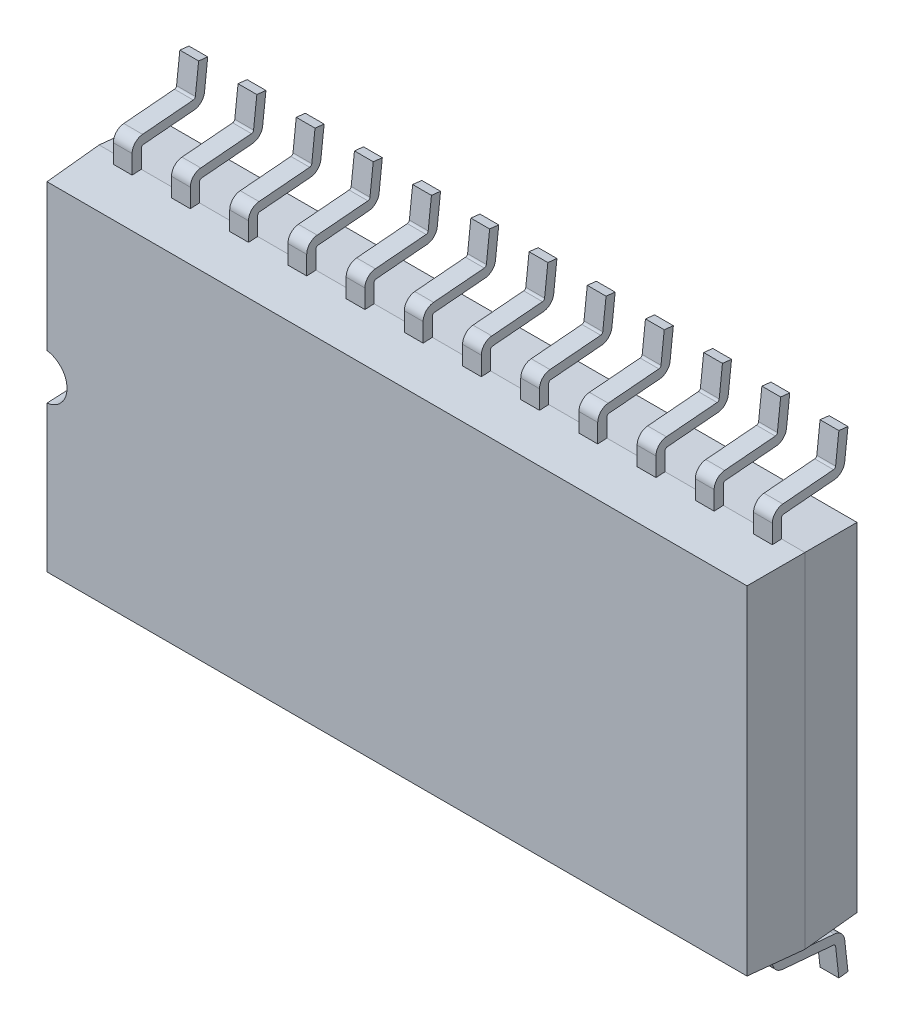
from build123d import *

# Parameters (mm, degrees)
SKETCH1_W             = 15.4
SKETCH1_H             = 7.5
BOSS_EXTRUDE1_DEPTH   = 1.2
BOSS_EXTRUDE1_TAPER   = 3
SKETCH2_W             = 15.4
SKETCH2_H             = 7.5
BOSS_EXTRUDE2_DEPTH   = 1.2
BOSS_EXTRUDE2_TAPER   = 3
EXTRUDE_THIN1_DEPTH   = 0.205
LPATTERN1_COUNT       = 12
LPATTERN1_PITCH       = 1.27
MIRROR1_COPY_1_DEPTH  = 0.205
MIRROR1_COPY_2_DEPTH  = 0.205
MIRROR1_COPY_3_DEPTH  = 0.205
MIRROR1_COPY_4_DEPTH  = 0.205
MIRROR1_COPY_5_DEPTH  = 0.205
MIRROR1_COPY_6_DEPTH  = 0.205
MIRROR1_COPY_7_DEPTH  = 0.205
MIRROR1_COPY_8_DEPTH  = 0.205
MIRROR1_COPY_9_DEPTH  = 0.205
MIRROR1_COPY_10_DEPTH = 0.205
MIRROR1_COPY_11_DEPTH = 0.205
CUT_EXTRUDE4_DEPTH    = 2.2


with BuildPart() as part:
    # Sketch1 → Boss-Extrude1 (new body)
    with BuildSketch(Plane.XY):
        with Locations((7.7, 3.75)):
            Rectangle(SKETCH1_W, SKETCH1_H)
    extrude(amount=BOSS_EXTRUDE1_DEPTH, taper=BOSS_EXTRUDE1_TAPER)

    # Sketch2 → Boss-Extrude2 (add)
    with BuildSketch(Plane(origin=(0, 0, 0), x_dir=(-1, 0, 0), z_dir=(0, 0, -1))):
        with Locations((-7.7, 3.75)):
            Rectangle(SKETCH2_W, SKETCH2_H)
    extrude(amount=BOSS_EXTRUDE2_DEPTH, taper=BOSS_EXTRUDE2_TAPER)

    # Sketch3 → Extrude-Thin1 (add, symmetric)
    with BuildSketch(Plane(origin=(0.715, 0, 0), x_dir=(0, 0, -1), z_dir=(1, 0, 0))):
        with BuildLine():
            Line((0, 0.17480102), (0, -0.397438223))
            ThreePointArc((0, -0.397438223), (0.013160257, -0.431244042), (0.045713334, -0.447254129))
            Line((0.045713334, -0.447254129), (1.151740198, -0.542427897))
            ThreePointArc((1.151740198, -0.542427897), (1.304800704, -0.612476978), (1.378754382, -0.763689564))
            Line((1.378754382, -0.763689564), (1.45, -1.4))
            Line((1.45, -1.4), (1.25124199, -1.422254291))
            Line((1.25124199, -1.422254291), (1.179996372, -0.785943854))
            ThreePointArc((1.179996372, -0.785943854), (1.165205636, -0.755701337), (1.134593535, -0.741691521))
            Line((1.134593535, -0.741691521), (0.028566671, -0.646517754))
            ThreePointArc((0.028566671, -0.646517754), (-0.134198714, -0.566467315), (-0.2, -0.397438223))
            Line((-0.2, -0.397438223), (-0.2, 0.17480102))
            Line((-0.2, 0.17480102), (0, 0.17480102))
        make_face()
    extrude_thin1 = extrude(amount=EXTRUDE_THIN1_DEPTH, both=True)

    # LPattern1: Extrude-Thin1 ×12
    with Locations(*[(i * LPATTERN1_PITCH, 0, 0) for i in range(1, LPATTERN1_COUNT)]):
        add(extrude_thin1)

    # Mirror1: Extrude-Thin1 across plane
    add(extrude_thin1.mirror(Plane.ZX.offset(3.75)))

    # Mirror1 copy 1 sketch → Mirror1 copy 1 (add, symmetric)
    with BuildSketch(Plane(origin=(1.985, 7.5, 0), x_dir=(0, 0, -1), z_dir=(1, 0, 0))):
        with BuildLine():
            Line((0, -0.17480102), (0, 0.397438223))
            ThreePointArc((0, 0.397438223), (0.013160257, 0.431244042), (0.045713334, 0.447254129))
            Line((0.045713334, 0.447254129), (1.151740198, 0.542427897))
            ThreePointArc((1.151740198, 0.542427897), (1.304800704, 0.612476978), (1.378754382, 0.763689564))
            Line((1.378754382, 0.763689564), (1.45, 1.4))
            Line((1.45, 1.4), (1.25124199, 1.422254291))
            Line((1.25124199, 1.422254291), (1.179996372, 0.785943854))
            ThreePointArc((1.179996372, 0.785943854), (1.165205636, 0.755701337), (1.134593535, 0.741691521))
            Line((1.134593535, 0.741691521), (0.028566671, 0.646517754))
            ThreePointArc((0.028566671, 0.646517754), (-0.134198714, 0.566467315), (-0.2, 0.397438223))
            Line((-0.2, 0.397438223), (-0.2, -0.17480102))
            Line((-0.2, -0.17480102), (0, -0.17480102))
        make_face()
    extrude(amount=MIRROR1_COPY_1_DEPTH, both=True)

    # Mirror1 copy 2 sketch → Mirror1 copy 2 (add, symmetric)
    with BuildSketch(Plane(origin=(3.255, 7.5, 0), x_dir=(0, 0, -1), z_dir=(1, 0, 0))):
        with BuildLine():
            Line((0, -0.17480102), (0, 0.397438223))
            ThreePointArc((0, 0.397438223), (0.013160257, 0.431244042), (0.045713334, 0.447254129))
            Line((0.045713334, 0.447254129), (1.151740198, 0.542427897))
            ThreePointArc((1.151740198, 0.542427897), (1.304800704, 0.612476978), (1.378754382, 0.763689564))
            Line((1.378754382, 0.763689564), (1.45, 1.4))
            Line((1.45, 1.4), (1.25124199, 1.422254291))
            Line((1.25124199, 1.422254291), (1.179996372, 0.785943854))
            ThreePointArc((1.179996372, 0.785943854), (1.165205636, 0.755701337), (1.134593535, 0.741691521))
            Line((1.134593535, 0.741691521), (0.028566671, 0.646517754))
            ThreePointArc((0.028566671, 0.646517754), (-0.134198714, 0.566467315), (-0.2, 0.397438223))
            Line((-0.2, 0.397438223), (-0.2, -0.17480102))
            Line((-0.2, -0.17480102), (0, -0.17480102))
        make_face()
    extrude(amount=MIRROR1_COPY_2_DEPTH, both=True)

    # Mirror1 copy 3 sketch → Mirror1 copy 3 (add, symmetric)
    with BuildSketch(Plane(origin=(4.525, 7.5, 0), x_dir=(0, 0, -1), z_dir=(1, 0, 0))):
        with BuildLine():
            Line((0, -0.17480102), (0, 0.397438223))
            ThreePointArc((0, 0.397438223), (0.013160257, 0.431244042), (0.045713334, 0.447254129))
            Line((0.045713334, 0.447254129), (1.151740198, 0.542427897))
            ThreePointArc((1.151740198, 0.542427897), (1.304800704, 0.612476978), (1.378754382, 0.763689564))
            Line((1.378754382, 0.763689564), (1.45, 1.4))
            Line((1.45, 1.4), (1.25124199, 1.422254291))
            Line((1.25124199, 1.422254291), (1.179996372, 0.785943854))
            ThreePointArc((1.179996372, 0.785943854), (1.165205636, 0.755701337), (1.134593535, 0.741691521))
            Line((1.134593535, 0.741691521), (0.028566671, 0.646517754))
            ThreePointArc((0.028566671, 0.646517754), (-0.134198714, 0.566467315), (-0.2, 0.397438223))
            Line((-0.2, 0.397438223), (-0.2, -0.17480102))
            Line((-0.2, -0.17480102), (0, -0.17480102))
        make_face()
    extrude(amount=MIRROR1_COPY_3_DEPTH, both=True)

    # Mirror1 copy 4 sketch → Mirror1 copy 4 (add, symmetric)
    with BuildSketch(Plane(origin=(5.795, 7.5, 0), x_dir=(0, 0, -1), z_dir=(1, 0, 0))):
        with BuildLine():
            Line((0, -0.17480102), (0, 0.397438223))
            ThreePointArc((0, 0.397438223), (0.013160257, 0.431244042), (0.045713334, 0.447254129))
            Line((0.045713334, 0.447254129), (1.151740198, 0.542427897))
            ThreePointArc((1.151740198, 0.542427897), (1.304800704, 0.612476978), (1.378754382, 0.763689564))
            Line((1.378754382, 0.763689564), (1.45, 1.4))
            Line((1.45, 1.4), (1.25124199, 1.422254291))
            Line((1.25124199, 1.422254291), (1.179996372, 0.785943854))
            ThreePointArc((1.179996372, 0.785943854), (1.165205636, 0.755701337), (1.134593535, 0.741691521))
            Line((1.134593535, 0.741691521), (0.028566671, 0.646517754))
            ThreePointArc((0.028566671, 0.646517754), (-0.134198714, 0.566467315), (-0.2, 0.397438223))
            Line((-0.2, 0.397438223), (-0.2, -0.17480102))
            Line((-0.2, -0.17480102), (0, -0.17480102))
        make_face()
    extrude(amount=MIRROR1_COPY_4_DEPTH, both=True)

    # Mirror1 copy 5 sketch → Mirror1 copy 5 (add, symmetric)
    with BuildSketch(Plane(origin=(7.065, 7.5, 0), x_dir=(0, 0, -1), z_dir=(1, 0, 0))):
        with BuildLine():
            Line((0, -0.17480102), (0, 0.397438223))
            ThreePointArc((0, 0.397438223), (0.013160257, 0.431244042), (0.045713334, 0.447254129))
            Line((0.045713334, 0.447254129), (1.151740198, 0.542427897))
            ThreePointArc((1.151740198, 0.542427897), (1.304800704, 0.612476978), (1.378754382, 0.763689564))
            Line((1.378754382, 0.763689564), (1.45, 1.4))
            Line((1.45, 1.4), (1.25124199, 1.422254291))
            Line((1.25124199, 1.422254291), (1.179996372, 0.785943854))
            ThreePointArc((1.179996372, 0.785943854), (1.165205636, 0.755701337), (1.134593535, 0.741691521))
            Line((1.134593535, 0.741691521), (0.028566671, 0.646517754))
            ThreePointArc((0.028566671, 0.646517754), (-0.134198714, 0.566467315), (-0.2, 0.397438223))
            Line((-0.2, 0.397438223), (-0.2, -0.17480102))
            Line((-0.2, -0.17480102), (0, -0.17480102))
        make_face()
    extrude(amount=MIRROR1_COPY_5_DEPTH, both=True)

    # Mirror1 copy 6 sketch → Mirror1 copy 6 (add, symmetric)
    with BuildSketch(Plane(origin=(8.335, 7.5, 0), x_dir=(0, 0, -1), z_dir=(1, 0, 0))):
        with BuildLine():
            Line((0, -0.17480102), (0, 0.397438223))
            ThreePointArc((0, 0.397438223), (0.013160257, 0.431244042), (0.045713334, 0.447254129))
            Line((0.045713334, 0.447254129), (1.151740198, 0.542427897))
            ThreePointArc((1.151740198, 0.542427897), (1.304800704, 0.612476978), (1.378754382, 0.763689564))
            Line((1.378754382, 0.763689564), (1.45, 1.4))
            Line((1.45, 1.4), (1.25124199, 1.422254291))
            Line((1.25124199, 1.422254291), (1.179996372, 0.785943854))
            ThreePointArc((1.179996372, 0.785943854), (1.165205636, 0.755701337), (1.134593535, 0.741691521))
            Line((1.134593535, 0.741691521), (0.028566671, 0.646517754))
            ThreePointArc((0.028566671, 0.646517754), (-0.134198714, 0.566467315), (-0.2, 0.397438223))
            Line((-0.2, 0.397438223), (-0.2, -0.17480102))
            Line((-0.2, -0.17480102), (0, -0.17480102))
        make_face()
    extrude(amount=MIRROR1_COPY_6_DEPTH, both=True)

    # Mirror1 copy 7 sketch → Mirror1 copy 7 (add, symmetric)
    with BuildSketch(Plane(origin=(9.605, 7.5, 0), x_dir=(0, 0, -1), z_dir=(1, 0, 0))):
        with BuildLine():
            Line((0, -0.17480102), (0, 0.397438223))
            ThreePointArc((0, 0.397438223), (0.013160257, 0.431244042), (0.045713334, 0.447254129))
            Line((0.045713334, 0.447254129), (1.151740198, 0.542427897))
            ThreePointArc((1.151740198, 0.542427897), (1.304800704, 0.612476978), (1.378754382, 0.763689564))
            Line((1.378754382, 0.763689564), (1.45, 1.4))
            Line((1.45, 1.4), (1.25124199, 1.422254291))
            Line((1.25124199, 1.422254291), (1.179996372, 0.785943854))
            ThreePointArc((1.179996372, 0.785943854), (1.165205636, 0.755701337), (1.134593535, 0.741691521))
            Line((1.134593535, 0.741691521), (0.028566671, 0.646517754))
            ThreePointArc((0.028566671, 0.646517754), (-0.134198714, 0.566467315), (-0.2, 0.397438223))
            Line((-0.2, 0.397438223), (-0.2, -0.17480102))
            Line((-0.2, -0.17480102), (0, -0.17480102))
        make_face()
    extrude(amount=MIRROR1_COPY_7_DEPTH, both=True)

    # Mirror1 copy 8 sketch → Mirror1 copy 8 (add, symmetric)
    with BuildSketch(Plane(origin=(10.875, 7.5, 0), x_dir=(0, 0, -1), z_dir=(1, 0, 0))):
        with BuildLine():
            Line((0, -0.17480102), (0, 0.397438223))
            ThreePointArc((0, 0.397438223), (0.013160257, 0.431244042), (0.045713334, 0.447254129))
            Line((0.045713334, 0.447254129), (1.151740198, 0.542427897))
            ThreePointArc((1.151740198, 0.542427897), (1.304800704, 0.612476978), (1.378754382, 0.763689564))
            Line((1.378754382, 0.763689564), (1.45, 1.4))
            Line((1.45, 1.4), (1.25124199, 1.422254291))
            Line((1.25124199, 1.422254291), (1.179996372, 0.785943854))
            ThreePointArc((1.179996372, 0.785943854), (1.165205636, 0.755701337), (1.134593535, 0.741691521))
            Line((1.134593535, 0.741691521), (0.028566671, 0.646517754))
            ThreePointArc((0.028566671, 0.646517754), (-0.134198714, 0.566467315), (-0.2, 0.397438223))
            Line((-0.2, 0.397438223), (-0.2, -0.17480102))
            Line((-0.2, -0.17480102), (0, -0.17480102))
        make_face()
    extrude(amount=MIRROR1_COPY_8_DEPTH, both=True)

    # Mirror1 copy 9 sketch → Mirror1 copy 9 (add, symmetric)
    with BuildSketch(Plane(origin=(12.145, 7.5, 0), x_dir=(0, 0, -1), z_dir=(1, 0, 0))):
        with BuildLine():
            Line((0, -0.17480102), (0, 0.397438223))
            ThreePointArc((0, 0.397438223), (0.013160257, 0.431244042), (0.045713334, 0.447254129))
            Line((0.045713334, 0.447254129), (1.151740198, 0.542427897))
            ThreePointArc((1.151740198, 0.542427897), (1.304800704, 0.612476978), (1.378754382, 0.763689564))
            Line((1.378754382, 0.763689564), (1.45, 1.4))
            Line((1.45, 1.4), (1.25124199, 1.422254291))
            Line((1.25124199, 1.422254291), (1.179996372, 0.785943854))
            ThreePointArc((1.179996372, 0.785943854), (1.165205636, 0.755701337), (1.134593535, 0.741691521))
            Line((1.134593535, 0.741691521), (0.028566671, 0.646517754))
            ThreePointArc((0.028566671, 0.646517754), (-0.134198714, 0.566467315), (-0.2, 0.397438223))
            Line((-0.2, 0.397438223), (-0.2, -0.17480102))
            Line((-0.2, -0.17480102), (0, -0.17480102))
        make_face()
    extrude(amount=MIRROR1_COPY_9_DEPTH, both=True)

    # Mirror1 copy 10 sketch → Mirror1 copy 10 (add, symmetric)
    with BuildSketch(Plane(origin=(13.415, 7.5, 0), x_dir=(0, 0, -1), z_dir=(1, 0, 0))):
        with BuildLine():
            Line((0, -0.17480102), (0, 0.397438223))
            ThreePointArc((0, 0.397438223), (0.013160257, 0.431244042), (0.045713334, 0.447254129))
            Line((0.045713334, 0.447254129), (1.151740198, 0.542427897))
            ThreePointArc((1.151740198, 0.542427897), (1.304800704, 0.612476978), (1.378754382, 0.763689564))
            Line((1.378754382, 0.763689564), (1.45, 1.4))
            Line((1.45, 1.4), (1.25124199, 1.422254291))
            Line((1.25124199, 1.422254291), (1.179996372, 0.785943854))
            ThreePointArc((1.179996372, 0.785943854), (1.165205636, 0.755701337), (1.134593535, 0.741691521))
            Line((1.134593535, 0.741691521), (0.028566671, 0.646517754))
            ThreePointArc((0.028566671, 0.646517754), (-0.134198714, 0.566467315), (-0.2, 0.397438223))
            Line((-0.2, 0.397438223), (-0.2, -0.17480102))
            Line((-0.2, -0.17480102), (0, -0.17480102))
        make_face()
    extrude(amount=MIRROR1_COPY_10_DEPTH, both=True)

    # Mirror1 copy 11 sketch → Mirror1 copy 11 (add, symmetric)
    with BuildSketch(Plane(origin=(14.685, 7.5, 0), x_dir=(0, 0, -1), z_dir=(1, 0, 0))):
        with BuildLine():
            Line((0, -0.17480102), (0, 0.397438223))
            ThreePointArc((0, 0.397438223), (0.013160257, 0.431244042), (0.045713334, 0.447254129))
            Line((0.045713334, 0.447254129), (1.151740198, 0.542427897))
            ThreePointArc((1.151740198, 0.542427897), (1.304800704, 0.612476978), (1.378754382, 0.763689564))
            Line((1.378754382, 0.763689564), (1.45, 1.4))
            Line((1.45, 1.4), (1.25124199, 1.422254291))
            Line((1.25124199, 1.422254291), (1.179996372, 0.785943854))
            ThreePointArc((1.179996372, 0.785943854), (1.165205636, 0.755701337), (1.134593535, 0.741691521))
            Line((1.134593535, 0.741691521), (0.028566671, 0.646517754))
            ThreePointArc((0.028566671, 0.646517754), (-0.134198714, 0.566467315), (-0.2, 0.397438223))
            Line((-0.2, 0.397438223), (-0.2, -0.17480102))
            Line((-0.2, -0.17480102), (0, -0.17480102))
        make_face()
    extrude(amount=MIRROR1_COPY_11_DEPTH, both=True)

    # Sketch5 → Cut-Extrude4 (cut, through all)
    with BuildSketch(Plane.XY):
        with BuildLine():
            Line((0, 4.25), (0, 3.25))
            ThreePointArc((0, 3.25), (0.5, 3.75), (0, 4.25))
        make_face()
    extrude(amount=CUT_EXTRUDE4_DEPTH, mode=Mode.SUBTRACT)


solid = part.part
